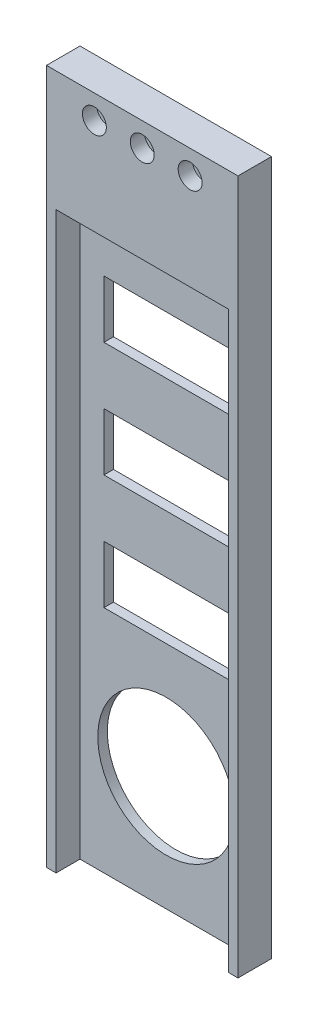
from build123d import *

# Parameters (mm, degrees)
SKETCH1_W           = 40
SKETCH1_H           = 145.1
BOSS_EXTRUDE1_DEPTH = 2
SKETCH2_R           = 14.29
CUT_EXTRUDE1_DEPTH  = 2
BOSS_EXTRUDE2_DEPTH = 5
SKETCH4_R           = 1.25
CUT_EXTRUDE2_DEPTH  = 7
SKETCH5_R           = 2.5
CUT_EXTRUDE3_DEPTH  = 3
SKETCH6_W           = 26
SKETCH6_H           = 12
CUT_EXTRUDE4_DEPTH  = 3


with BuildPart() as part:
    # Sketch1 → Boss-Extrude1 (new body)
    with BuildSketch(Plane.XY):
        with Locations((20, 72.55)):
            Rectangle(SKETCH1_W, SKETCH1_H)
    extrude(amount=BOSS_EXTRUDE1_DEPTH)

    # Sketch2 → Cut-Extrude1 (cut)
    with BuildSketch(Plane.XY.offset(2)):
        with Locations((20, 24)):
            Circle(SKETCH2_R)
    extrude(amount=-CUT_EXTRUDE1_DEPTH, mode=Mode.SUBTRACT)

    # Sketch3 → Boss-Extrude2 (add)
    with BuildSketch(Plane.XY.offset(2)):
        Polygon((0, 145.1), (40, 145.1), (40, 0), (38, 0), (38, 120), (2, 120), (2, 0), (0, 0), align=None)
    extrude(amount=BOSS_EXTRUDE2_DEPTH)

    # Sketch4 → Cut-Extrude2 (cut)
    with BuildSketch(Plane.XY.offset(7)):
        with Locations((20, 140.1)):
            Circle(SKETCH4_R)
        with Locations((10, 140.1)):
            Circle(SKETCH4_R)
        with Locations((30, 140.1)):
            Circle(SKETCH4_R)
    extrude(amount=-CUT_EXTRUDE2_DEPTH, mode=Mode.SUBTRACT)

    # Sketch5 → Cut-Extrude3 (cut)
    with BuildSketch(Plane.XY.offset(7)):
        with Locations((10, 140.1)):
            Circle(SKETCH5_R)
        with Locations((20, 140.1)):
            Circle(SKETCH5_R)
        with Locations((30, 140.1)):
            Circle(SKETCH5_R)
    extrude(amount=-CUT_EXTRUDE3_DEPTH, mode=Mode.SUBTRACT)

    # Sketch6 → Cut-Extrude4 (cut, through all)
    with BuildSketch(Plane.XY.offset(2)):
        with Locations((20, 102)):
            Rectangle(SKETCH6_W, SKETCH6_H)
        with Locations((20, 78)):
            Rectangle(SKETCH6_W, SKETCH6_H)
        with Locations((20, 54)):
            Rectangle(SKETCH6_W, SKETCH6_H)
    extrude(amount=-CUT_EXTRUDE4_DEPTH, mode=Mode.SUBTRACT)


solid = part.part
